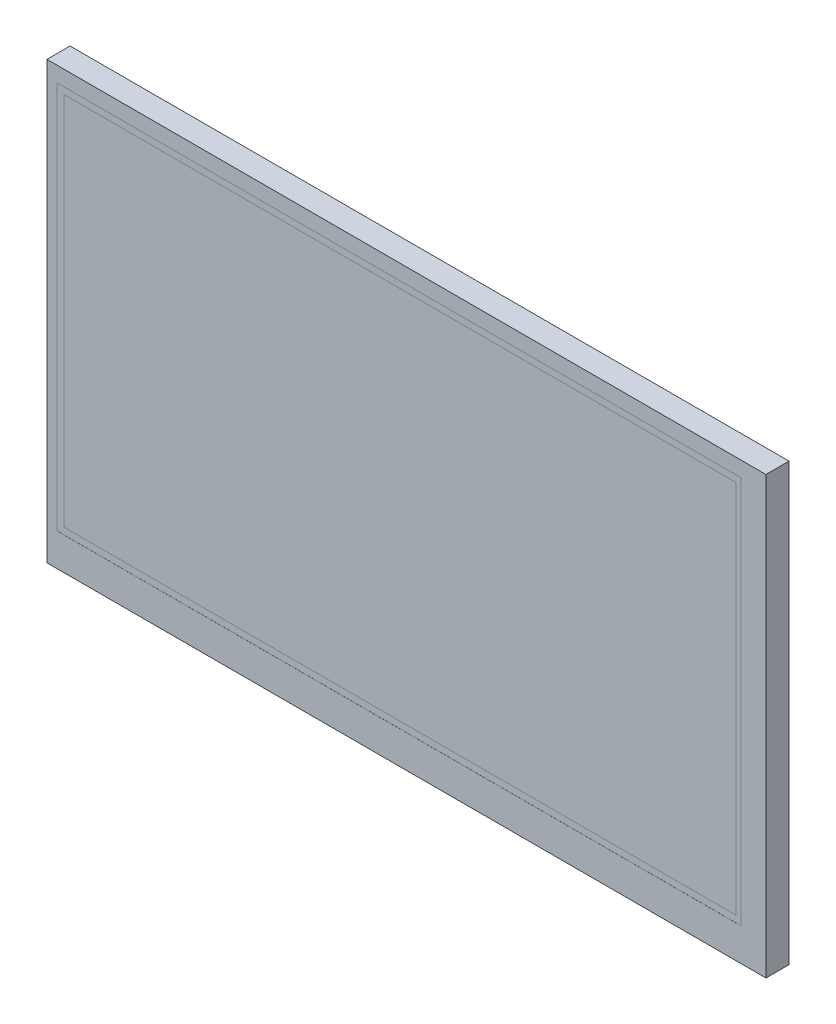
from build123d import *

# Parameters (mm, degrees)
SKETCH2_W                  = 180
SKETCH2_H                  = 104
PCB_DEPTH                  = 1.6
F_3_2_3_2_DIAMETER_HOLE1_D = 3.2
SKETCH5_W                  = 164.9
SKETCH5_H                  = 100
BEZEL_DEPTH                = 3.7
SKETCH6_W                  = 156.9
SKETCH6_H                  = 89
VISUAL_AREA_VA_DEPTH       = 0.01
F_1_0_1_DIAMETER_HOLE1_D   = 1
SKETCH12_W                 = 180
SKETCH12_H                 = 104
SKETCH12_W_2               = 164.9
SKETCH12_H_2               = 100
CUT_EXTRUDE1_DEPTH         = 6.3


with BuildPart() as part:
    # Sketch2 → PCB (new body)
    with BuildSketch(Plane.XY):
        Rectangle(SKETCH2_W, SKETCH2_H)
    extrude(amount=PCB_DEPTH)

    # Ø3.2 (3.2) Diameter Hole1 (through all)
    with Locations(Plane.XY.offset(1.6)):
        with Locations((-87, 49), (87, 49), (87, -49), (-87, -49)):
            Hole(F_3_2_3_2_DIAMETER_HOLE1_D / 2)

    # Sketch5 → Bezel (add)
    with BuildSketch(Plane.XY.offset(1.6)):
        Rectangle(SKETCH5_W, SKETCH5_H)
    extrude(amount=BEZEL_DEPTH)

    # Sketch6 → Visual Area (VA) (cut)
    with BuildSketch(Plane.XY.offset(5.3)):
        with Locations((-1.7, 2)):
            Rectangle(SKETCH6_W, SKETCH6_H)
    extrude(amount=-VISUAL_AREA_VA_DEPTH, mode=Mode.SUBTRACT)

    # Ø1.0 (1) Diameter Hole1 (through all)
    with Locations(Plane.XY.offset(1.6)):
        with Locations((88.5, -41.91), (85.96, -41.91), (85.96, -39.37), (85.96, -36.83), (85.96, -34.29), (88.5, -39.37), (88.5, -36.83), (88.5, -34.29), (88.5, -24.13), (85.96, -24.13), (85.96, -21.59), (85.96, -19.05), (85.96, -16.51), (85.96, -13.97), (85.96, -11.43), (85.96, -8.89), (85.96, -6.35), (85.96, -3.81), (85.96, -1.27), (85.96, 1.27), (85.96, 3.81), (85.96, 6.35), (85.96, 8.89), (85.96, 11.43), (85.96, 13.97), (85.96, 16.51), (85.96, 19.05), (85.96, 21.59), (85.96, 24.13), (88.5, -21.59), (88.5, -19.05), (88.5, -16.51), (88.5, -13.97), (88.5, -11.43), (88.5, -8.89), (88.5, -6.35), (88.5, -3.81), (88.5, -1.27), (88.5, 1.27), (88.5, 3.81), (88.5, 6.35), (88.5, 8.89), (88.5, 11.43), (88.5, 13.97), (88.5, 16.51), (88.5, 19.05), (88.5, 21.59), (88.5, 24.13), (88.5, 34.29), (85.96, 34.29), (85.96, 36.83), (85.96, 39.37), (85.96, 41.91), (88.5, 36.83), (88.5, 39.37), (88.5, 41.91)):
            Hole(F_1_0_1_DIAMETER_HOLE1_D / 2)

    # Sketch12 → Cut-Extrude1 (cut, through all)
    with BuildSketch(Plane.XY.offset(5.3)):
        Rectangle(SKETCH12_W, SKETCH12_H)
        Rectangle(SKETCH12_W_2, SKETCH12_H_2, mode=Mode.SUBTRACT)
    extrude(amount=-CUT_EXTRUDE1_DEPTH, mode=Mode.SUBTRACT)


solid = part.part
